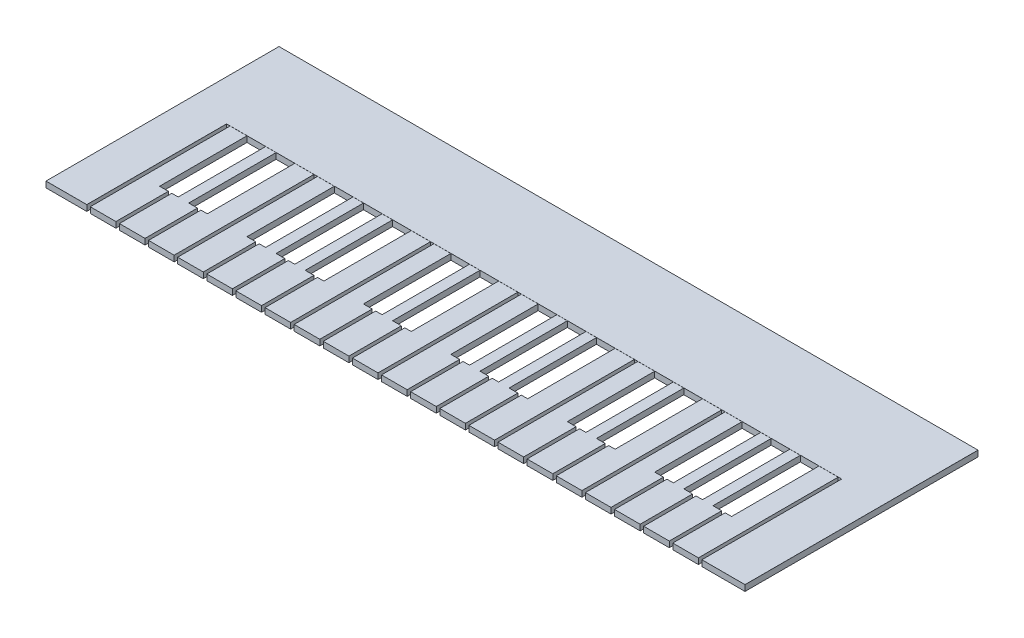
from build123d import *

# Parameters (mm, degrees)
SKETCH1_W           = 600
SKETCH1_H           = 200
BOSS_EXTRUDE1_DEPTH = 5
SKETCH2_W           = 3
SKETCH2_H           = 120
CUT_EXTRUDE4_DEPTH  = 5
SKETCH4_W           = 16
SKETCH4_H           = 75
CUT_EXTRUDE5_DEPTH  = 5
BOSS_EXTRUDE2_DEPTH = 0.1


with BuildPart() as part:
    # Sketch1 → Boss-Extrude1 (new body)
    with BuildSketch(Plane(origin=(0, 0, 0), x_dir=(1, 0, 0), z_dir=(0, 1, 0))):
        with Locations((300, 100)):
            Rectangle(SKETCH1_W, SKETCH1_H)
    extrude(amount=BOSS_EXTRUDE1_DEPTH)

    # Sketch2 → Cut-Extrude4 (cut)
    with BuildSketch(Plane(origin=(0, 5, 0), x_dir=(1, 0, 0), z_dir=(0, 1, 0))):
        with Locations((36.5, 60)):
            Rectangle(SKETCH2_W, SKETCH2_H)
        with Locations((61.5, 60)):
            Rectangle(SKETCH2_W, SKETCH2_H)
        with Locations((86.5, 60)):
            Rectangle(SKETCH2_W, SKETCH2_H)
        with Locations((111.5, 60)):
            Rectangle(SKETCH2_W, SKETCH2_H)
        with Locations((136.5, 60)):
            Rectangle(SKETCH2_W, SKETCH2_H)
        with Locations((161.5, 60)):
            Rectangle(SKETCH2_W, SKETCH2_H)
        with Locations((186.5, 60)):
            Rectangle(SKETCH2_W, SKETCH2_H)
        with Locations((211.5, 60)):
            Rectangle(SKETCH2_W, SKETCH2_H)
        with Locations((236.5, 60)):
            Rectangle(SKETCH2_W, SKETCH2_H)
        with Locations((261.5, 60)):
            Rectangle(SKETCH2_W, SKETCH2_H)
        with Locations((286.5, 60)):
            Rectangle(SKETCH2_W, SKETCH2_H)
        with Locations((311.5, 60)):
            Rectangle(SKETCH2_W, SKETCH2_H)
        with Locations((336.5, 60)):
            Rectangle(SKETCH2_W, SKETCH2_H)
        with Locations((361.5, 60)):
            Rectangle(SKETCH2_W, SKETCH2_H)
        with Locations((386.5, 60)):
            Rectangle(SKETCH2_W, SKETCH2_H)
        with Locations((411.5, 60)):
            Rectangle(SKETCH2_W, SKETCH2_H)
        with Locations((436.5, 60)):
            Rectangle(SKETCH2_W, SKETCH2_H)
        with Locations((461.5, 60)):
            Rectangle(SKETCH2_W, SKETCH2_H)
        with Locations((486.5, 60)):
            Rectangle(SKETCH2_W, SKETCH2_H)
        with Locations((511.5, 60)):
            Rectangle(SKETCH2_W, SKETCH2_H)
        with Locations((536.5, 60)):
            Rectangle(SKETCH2_W, SKETCH2_H)
        with Locations((561.5, 60)):
            Rectangle(SKETCH2_W, SKETCH2_H)
    extrude(amount=-CUT_EXTRUDE4_DEPTH, mode=Mode.SUBTRACT)

    # Sketch4 → Cut-Extrude5 (cut)
    with BuildSketch(Plane(origin=(0, 5, 0), x_dir=(1, 0, 0), z_dir=(0, 1, 0))):
        with Locations((60.5, 82.5)):
            Rectangle(SKETCH4_W, SKETCH4_H)
        with Locations((85.5, 82.5)):
            Rectangle(SKETCH4_W, SKETCH4_H)
        with Locations((135.5, 82.5)):
            Rectangle(SKETCH4_W, SKETCH4_H)
        with Locations((160.5, 82.5)):
            Rectangle(SKETCH4_W, SKETCH4_H)
        with Locations((185.5, 82.5)):
            Rectangle(SKETCH4_W, SKETCH4_H)
        with Locations((235.5, 82.5)):
            Rectangle(SKETCH4_W, SKETCH4_H)
        with Locations((260.5, 82.5)):
            Rectangle(SKETCH4_W, SKETCH4_H)
        with Locations((310.5, 82.5)):
            Rectangle(SKETCH4_W, SKETCH4_H)
        with Locations((335.5, 82.5)):
            Rectangle(SKETCH4_W, SKETCH4_H)
        with Locations((360.5, 82.5)):
            Rectangle(SKETCH4_W, SKETCH4_H)
        with Locations((410.5, 82.5)):
            Rectangle(SKETCH4_W, SKETCH4_H)
        with Locations((435.5, 82.5)):
            Rectangle(SKETCH4_W, SKETCH4_H)
        with Locations((485.5, 82.5)):
            Rectangle(SKETCH4_W, SKETCH4_H)
        with Locations((510.5, 82.5)):
            Rectangle(SKETCH4_W, SKETCH4_H)
        with Locations((535.5, 82.5)):
            Rectangle(SKETCH4_W, SKETCH4_H)
    extrude(amount=-CUT_EXTRUDE5_DEPTH, mode=Mode.SUBTRACT)


with BuildPart() as body_2:
    # Sketch5 → Boss-Extrude2 (new body)
    with BuildSketch(Plane(origin=(0, 5, 0), x_dir=(1, 0, 0), z_dir=(0, 1, 0))):
        Polygon((0, 0), (35, 0), (35, 120), (563, 120), (563, 0), (600, 0), (600, 120), (600, 200), (0, 200), (0, 120), align=None)
    extrude(amount=BOSS_EXTRUDE2_DEPTH)


solid = Compound([part.part, body_2.part])
